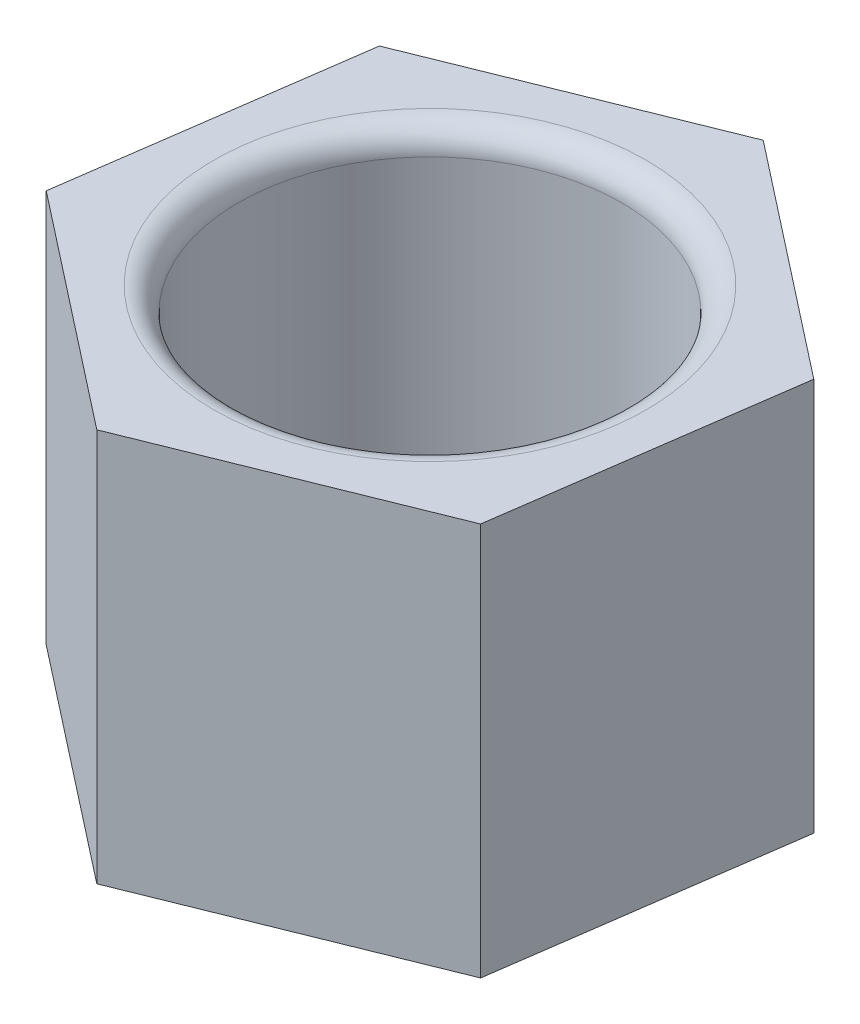
from build123d import *

# Parameters (mm, degrees)
BOSS_EXTRUDE1_DEPTH = 4
SKETCH2_R           = 1.95
CUT_EXTRUDE1_DEPTH  = 3
FILLET1_R           = 0.25


with BuildPart() as part:
    # Sketch1 → Boss-Extrude1 (new body)
    with BuildSketch(Plane(origin=(0, 0, 0), x_dir=(1, 0, 0), z_dir=(0, 1, 0))):
        Polygon((2.362917062, -1.848410928), (2.782229351, 1.122140739), (0.419312289, 2.970551667), (-2.362917062, 1.848410928), (-2.782229351, -1.122140739), (-0.419312289, -2.970551667), align=None)
    extrude(amount=BOSS_EXTRUDE1_DEPTH)

    # Sketch2 → Cut-Extrude1 (cut)
    with BuildSketch(Plane(origin=(0, 4, 0), x_dir=(1, 0, 0), z_dir=(0, 1, 0))):
        Circle(SKETCH2_R)
    extrude(amount=-CUT_EXTRUDE1_DEPTH, mode=Mode.SUBTRACT)

    # Fillet1
    fillet1_edges = [part.edges().sort_by_distance(p)[0] for p in [
        (-1.95, 4, 0),
    ]]
    fillet(fillet1_edges, radius=FILLET1_R)


solid = part.part
